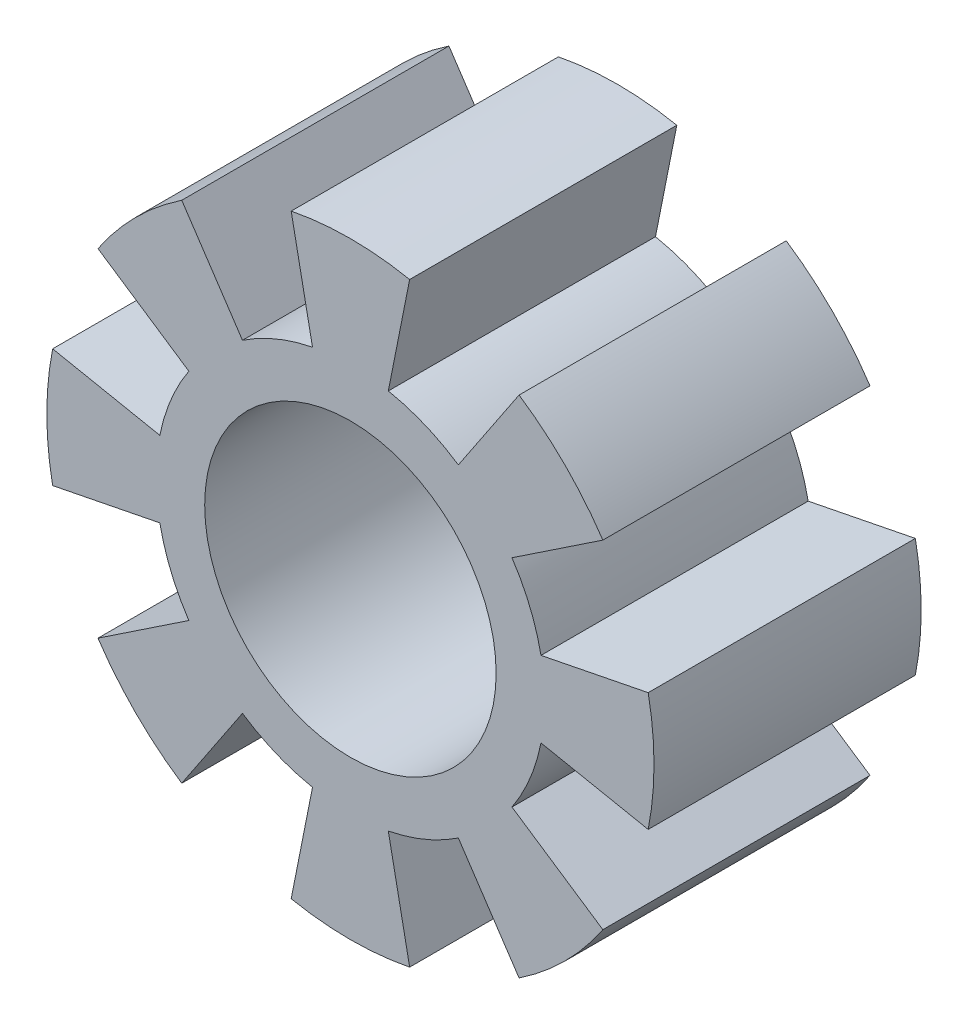
from build123d import *

# Parameters (mm, degrees)
SKETCH_1_R      = 6
EXTRUDE_1_DEPTH = 11


with BuildPart() as part:
    # 草图1 → 凸台-拉伸1 (new body)
    with BuildSketch(Plane.XY):
        with BuildLine():
            Line((-2.438629025, 12.259816005), (-1.560722576, 7.846282243))
            ThreePointArc((-1.560722576, 7.846282243), (-3.061467459, 7.39103626), (-4.444561864, 6.651756898))
            Line((-4.444561864, 6.651756898), (-6.944627913, 10.393370154))
            ThreePointArc((-6.944627913, 10.393370154), (-8.838834765, 8.838834765), (-10.393370154, 6.944627913))
            Line((-10.393370154, 6.944627913), (-6.651756898, 4.444561864))
            ThreePointArc((-6.651756898, 4.444561864), (-7.39103626, 3.061467459), (-7.846282243, 1.560722576))
            Line((-7.846282243, 1.560722576), (-12.259816005, 2.438629025))
            ThreePointArc((-12.259816005, 2.438629025), (-12.5, 0), (-12.259816005, -2.438629025))
            Line((-12.259816005, -2.438629025), (-7.846282243, -1.560722576))
            ThreePointArc((-7.846282243, -1.560722576), (-7.39103626, -3.061467459), (-6.651756898, -4.444561864))
            Line((-6.651756898, -4.444561864), (-10.393370154, -6.944627913))
            ThreePointArc((-10.393370154, -6.944627913), (-8.838834765, -8.838834765), (-6.944627913, -10.393370154))
            Line((-6.944627913, -10.393370154), (-4.444561864, -6.651756898))
            ThreePointArc((-4.444561864, -6.651756898), (-3.061467459, -7.39103626), (-1.560722576, -7.846282243))
            Line((-1.560722576, -7.846282243), (-2.438629025, -12.259816005))
            ThreePointArc((-2.438629025, -12.259816005), (0, -12.5), (2.438629025, -12.259816005))
            Line((2.438629025, -12.259816005), (1.560722576, -7.846282243))
            ThreePointArc((1.560722576, -7.846282243), (3.061467459, -7.39103626), (4.444561864, -6.651756898))
            Line((4.444561864, -6.651756898), (6.944627913, -10.393370154))
            ThreePointArc((6.944627913, -10.393370154), (8.838834765, -8.838834765), (10.393370154, -6.944627913))
            Line((10.393370154, -6.944627913), (6.651756898, -4.444561864))
            ThreePointArc((6.651756898, -4.444561864), (7.39103626, -3.061467459), (7.846282243, -1.560722576))
            Line((7.846282243, -1.560722576), (12.259816005, -2.438629025))
            ThreePointArc((12.259816005, -2.438629025), (12.5, 0), (12.259816005, 2.438629025))
            Line((12.259816005, 2.438629025), (7.846282243, 1.560722576))
            ThreePointArc((7.846282243, 1.560722576), (7.39103626, 3.061467459), (6.651756898, 4.444561864))
            Line((6.651756898, 4.444561864), (10.393370154, 6.944627913))
            ThreePointArc((10.393370154, 6.944627913), (8.838834765, 8.838834765), (6.944627913, 10.393370154))
            Line((6.944627913, 10.393370154), (4.444561864, 6.651756898))
            ThreePointArc((4.444561864, 6.651756898), (3.061467459, 7.39103626), (1.560722576, 7.846282243))
            Line((1.560722576, 7.846282243), (2.438629025, 12.259816005))
            ThreePointArc((2.438629025, 12.259816005), (0, 12.5), (-2.438629025, 12.259816005))
        make_face()
        Circle(SKETCH_1_R, mode=Mode.SUBTRACT)
    extrude(amount=EXTRUDE_1_DEPTH)


solid = part.part
